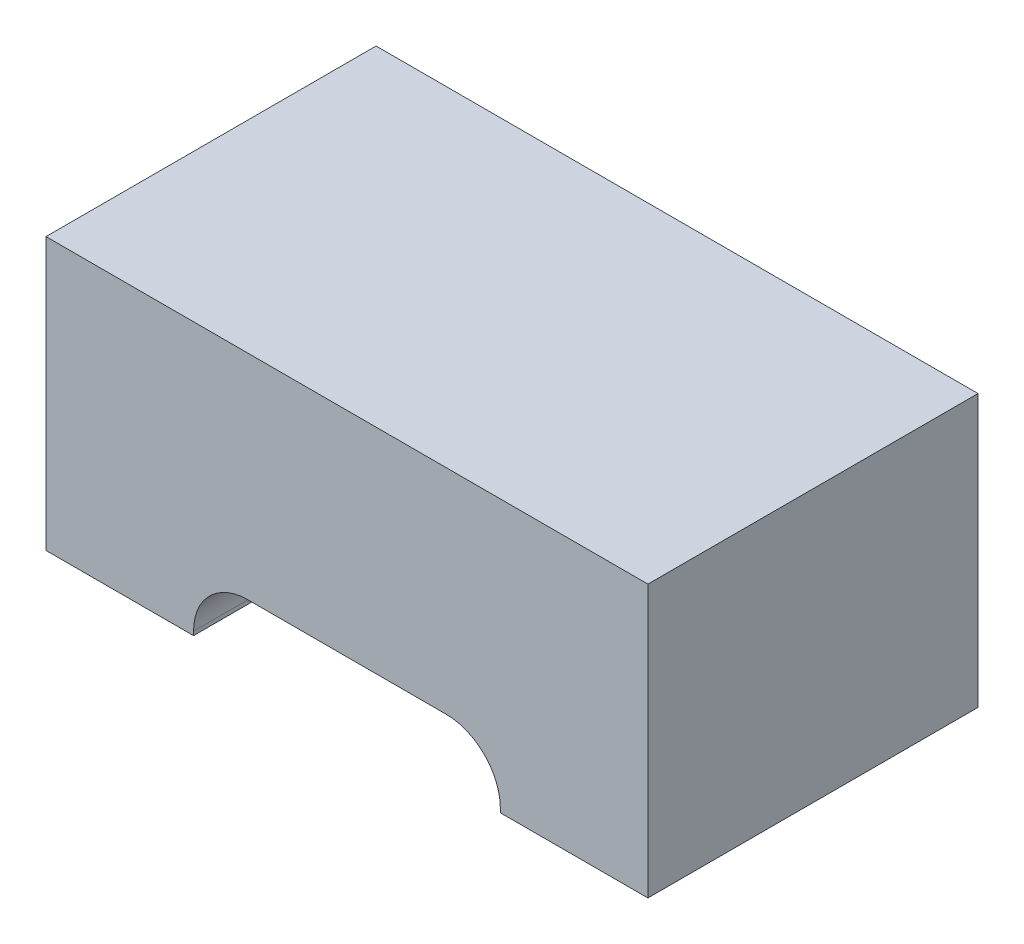
from build123d import *

# Parameters (mm, degrees)
SKETCH1_W               = 1.55
SKETCH1_H               = 0.85
BOSS_EXTRUDE1_DEPTH     = 0.7
CUT_EXTRUDE1_DEPTH      = 1.425
CUT_EXTRUDE1_DEPTH_BACK = 1.425


with BuildPart() as part:
    # Sketch1 → Boss-Extrude1 (new body)
    with BuildSketch(Plane(origin=(0, 0, 0), x_dir=(1, 0, 0), z_dir=(0, 1, 0))):
        Rectangle(SKETCH1_W, SKETCH1_H)
    extrude(amount=BOSS_EXTRUDE1_DEPTH)

    # Sketch2 → Cut-Extrude1 (cut, two sides)
    with BuildSketch(Plane.XY) as cut_extrude1_sk:
        with BuildLine():
            Line((-0.255, 0.15), (0.255, 0.15))
            ThreePointArc((0.255, 0.15), (0.353994949, 0.108994949), (0.395, 0.01))
            Line((0.395, 0.01), (0.395, 0))
            Line((0.395, 0), (-0.395, 0))
            Line((-0.395, 0), (-0.395, 0.01))
            ThreePointArc((-0.395, 0.01), (-0.353994949, 0.108994949), (-0.255, 0.15))
        make_face()
    extrude(amount=CUT_EXTRUDE1_DEPTH, mode=Mode.SUBTRACT)
    extrude(cut_extrude1_sk.sketch, amount=-CUT_EXTRUDE1_DEPTH_BACK, mode=Mode.SUBTRACT)


solid = part.part
